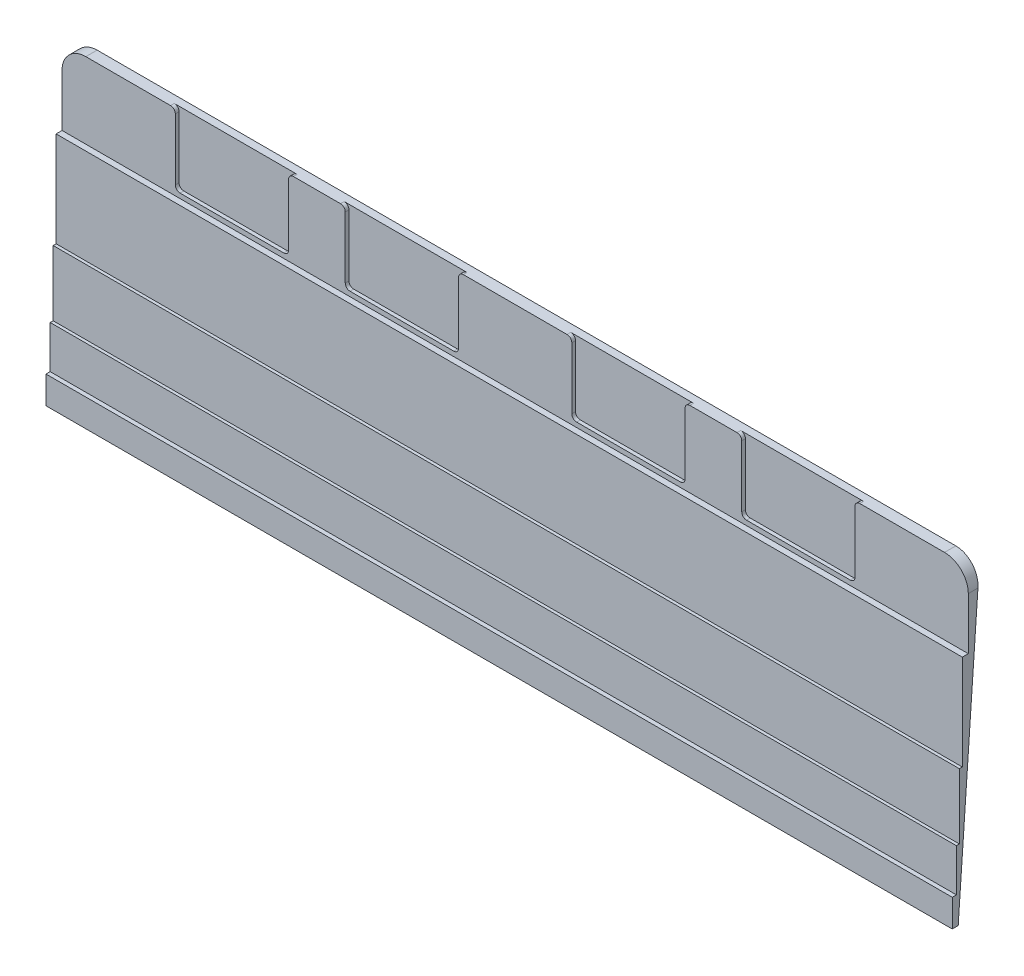
from build123d import *

# Parameters (mm, degrees)
BOSS_EXTRUDE1_DEPTH = 304.800275
FILLET1_R           = 8
SKETCH2_W           = 38.10085
SKETCH2_H           = 23.904524524
SKETCH2_W_2         = 38.1
CUT_EXTRUDE1_DEPTH  = 1.25
FILLET2_R           = 1.6
FILLET3_R           = 1.6


with BuildPart() as part:
    # Sketch1 → Boss-Extrude1 (new body)
    with BuildSketch(Plane.ZY.offset(149.225)):
        Polygon((-2, -64.3742065), (-3.3962, -64.3742065), (-3.3962, -50.048837521), (-4.3962, -50.048837521), (-4.3962, -28.126347), (-5.3962, -28.126347), (-5.3962, 3.873653), (-7.3962, 3.873653), (-7.3962, 29.378177524), (-11.202667042, 29.378177524), (-4, -73.62476), (-2, -73.62476), align=None)
    extrude(amount=-BOSS_EXTRUDE1_DEPTH)

    # Fillet1
    fillet1_edges = [part.edges().sort_by_distance(p)[0] for p in [
        (-149.225, 29.378177524, -9.299433521),
        (155.575275, 29.378177524, -9.299433521),
    ]]
    fillet(fillet1_edges, radius=FILLET1_R)

    # Sketch2 → Cut-Extrude1 (cut)
    with BuildSketch(Plane.XY.offset(-7.3962)):
        with Locations((41.2757, 17.425915262)):
            Rectangle(SKETCH2_W, SKETCH2_H)
        with Locations((-92.074875, 17.425915262)):
            Rectangle(SKETCH2_W_2, SKETCH2_H)
        with Locations((-34.92515, 17.425915262)):
            Rectangle(SKETCH2_W, SKETCH2_H)
        with Locations((98.425425, 17.425915262)):
            Rectangle(SKETCH2_W_2, SKETCH2_H)
    extrude(amount=-CUT_EXTRUDE1_DEPTH, mode=Mode.SUBTRACT)

    # Fillet2
    fillet2_edges = [part.edges().sort_by_distance(p)[0] for p in [
        (-111.124875, 5.473653, -8.0212),
        (-73.024875, 5.473653, -8.0212),
        (-53.975575, 5.473653, -8.0212),
        (-15.874725, 5.473653, -8.0212),
        (60.326125, 5.473653, -8.0212),
        (22.225275, 5.473653, -8.0212),
        (117.475425, 5.473653, -8.0212),
        (79.375425, 5.473653, -8.0212),
    ]]
    fillet(fillet2_edges, radius=FILLET2_R)

    # Fillet3
    fillet3_edges = [part.edges().sort_by_distance(p)[0] for p in [
        (-111.124875, 29.378177524, -8.0212),
        (-73.024875, 29.378177524, -8.0212),
        (-53.975575, 29.378177524, -8.0212),
        (-15.874725, 29.378177524, -8.0212),
        (22.225275, 29.378177524, -8.0212),
        (60.326125, 29.378177524, -8.0212),
        (79.375425, 29.378177524, -8.0212),
        (117.475425, 29.378177524, -8.0212),
    ]]
    fillet(fillet3_edges, radius=FILLET3_R)


solid = part.part
